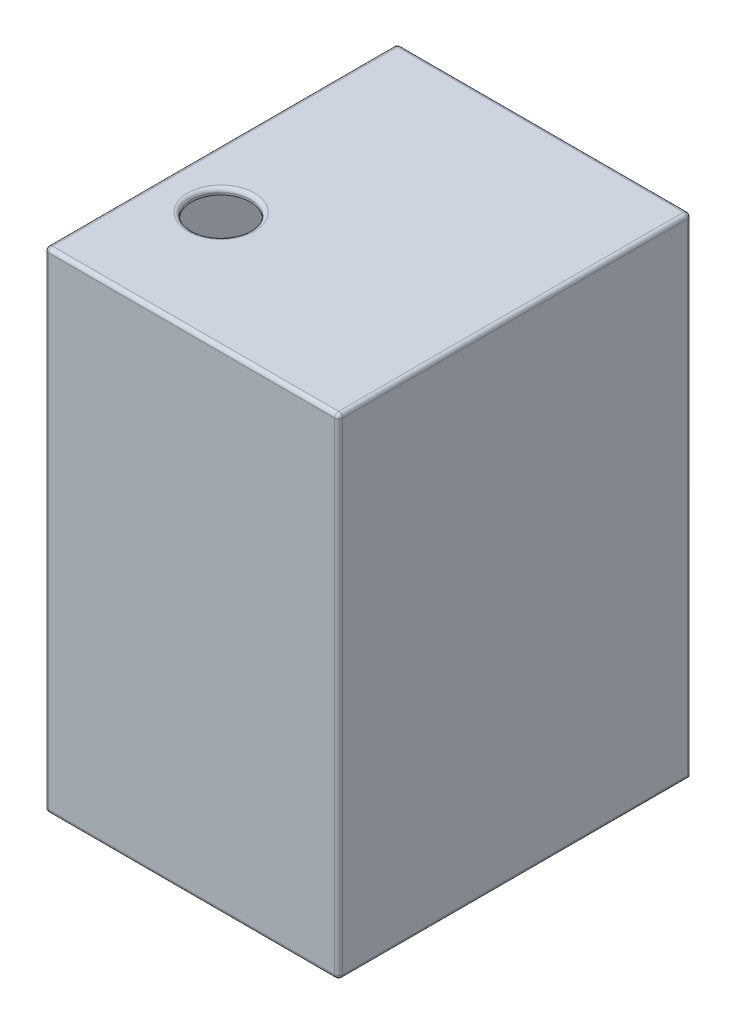
from build123d import *

# Parameters (mm, degrees)
SKETCH1_W           = 150
SKETCH1_H           = 250
BOSS_EXTRUDE1_DEPTH = 180
SHELL1_T            = -3
SKETCH2_W           = 150
SKETCH2_H           = 3
BOSS_EXTRUDE2_DEPTH = 180
SKETCH3_R           = 15
CUT_EXTRUDE1_DEPTH  = 10
FILLET1_R           = 2
SKETCH9_R           = 13
CUT_EXTRUDE2_DEPTH  = 15
BOSS_EXTRUDE3_START = 40
SKETCH9_3_R         = 15
SKETCH9_3_R_2       = 13
BOSS_EXTRUDE3_DEPTH = 40


with BuildPart() as part:
    # Sketch1 → Boss-Extrude1 (new body)
    with BuildSketch(Plane.XY):
        with Locations((75, -125)):
            Rectangle(SKETCH1_W, SKETCH1_H)
    extrude(amount=BOSS_EXTRUDE1_DEPTH)

    # Shell1
    shell1_openings = [part.faces().sort_by_distance(p)[0] for p in [
        (75, 0, 90),
    ]]
    offset(amount=SHELL1_T, openings=shell1_openings, kind=Kind.INTERSECTION)

    # Sketch2 → Boss-Extrude2 (add)
    with BuildSketch(Plane.XY):
        with Locations((75, -1.5)):
            Rectangle(SKETCH2_W, SKETCH2_H)
    extrude(amount=BOSS_EXTRUDE2_DEPTH)

    # Sketch3 → Cut-Extrude1 (cut)
    with BuildSketch(Plane(origin=(0, 0, 0), x_dir=(1, 0, 0), z_dir=(0, 1, 0))):
        with Locations((30, -120)):
            Circle(SKETCH3_R)
    extrude(amount=-CUT_EXTRUDE1_DEPTH, mode=Mode.SUBTRACT)

    # Fillet1
    fillet1_edges = [part.edges().sort_by_distance(p)[0] for p in [
        (0, 0, 90),
        (150, 0, 90),
        (0, -250, 90),
        (150, -250, 90),
        (0, -125, 0),
        (150, -125, 0),
        (75, 0, 0),
        (75, 0, 180),
        (150, -125, 180),
        (75, -250, 180),
        (0, -125, 180),
        (15, 0, 120),
    ]]
    fillet(fillet1_edges, radius=FILLET1_R)

    # Sketch9 → Cut-Extrude2 (cut)
    with BuildSketch(Plane(origin=(0, 0, 0), x_dir=(-1, 0, 0), z_dir=(0, 0, -1))):
        with Locations((-70, -235)):
            Circle(SKETCH9_R)
    extrude(amount=-CUT_EXTRUDE2_DEPTH, mode=Mode.SUBTRACT)

    # Sketch9_3 → Boss-Extrude3 (add)
    with BuildSketch(Plane(origin=(0, 0, 0), x_dir=(-1, 0, 0), z_dir=(0, 0, -1)).offset(BOSS_EXTRUDE3_START)):
        with Locations((-70, -235)):
            Circle(SKETCH9_3_R)
        with Locations((-70, -235)):
            Circle(SKETCH9_3_R_2, mode=Mode.SUBTRACT)
    extrude(amount=-BOSS_EXTRUDE3_DEPTH)


solid = part.part
